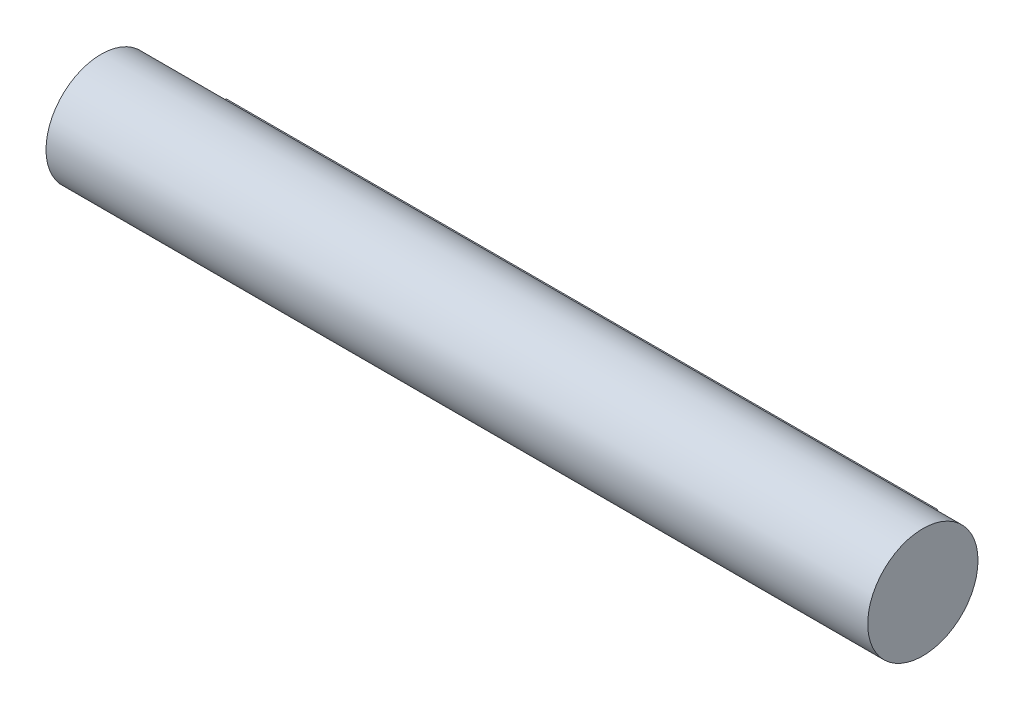
from build123d import *

# Parameters (mm, degrees)
BOSS_EXTRUDE1_DEPTH = 491.49
SKETCH2_R           = 38.1
BOSS_EXTRUDE2_DEPTH = 38.1
SKETCH3_R           = 38.1
BOSS_EXTRUDE3_DEPTH = 38.1


with BuildPart() as part:
    # Sketch1 → Boss-Extrude1 (new body)
    with BuildSketch(Plane(origin=(0, 0, 0), x_dir=(0, 0, -1), z_dir=(1, 0, 0))):
        with BuildLine():
            Line((27.94, 6.35), (27.94, -6.35))
            Line((27.94, -6.35), (37.567106623, -6.35))
            ThreePointArc((37.567106623, -6.35), (37.966542918, -3.186160517), (38.1, 0))
            ThreePointArc((38.1, 0), (37.966542918, 3.186160517), (37.567106623, 6.35))
            Line((37.567106623, 6.35), (27.94, 6.35))
        make_face()
        with BuildLine():
            Line((37.567106623, -6.35), (27.94, -6.35))
            Line((27.94, -6.35), (27.94, 6.35))
            Line((27.94, 6.35), (37.567106623, 6.35))
            ThreePointArc((37.567106623, 6.35), (-38.1, 0), (37.567106623, -6.35))
        make_face()
        with BuildLine():
            ThreePointArc((38.1, 0), (37.966542918, -3.186160517), (37.567106623, -6.35))
            Line((37.567106623, -6.35), (48.26, -6.35))
            Line((48.26, -6.35), (48.26, 6.35))
            Line((48.26, 6.35), (37.567106623, 6.35))
            ThreePointArc((37.567106623, 6.35), (37.966542918, 3.186160517), (38.1, 0))
        make_face()
    extrude(amount=-BOSS_EXTRUDE1_DEPTH)

    # Sketch2 → Boss-Extrude2 (add)
    with BuildSketch(Plane(origin=(0, 0, 0), x_dir=(0, 0, -1), z_dir=(1, 0, 0))):
        Circle(SKETCH2_R)
    extrude(amount=BOSS_EXTRUDE2_DEPTH)

    # Sketch3 → Boss-Extrude3 (add)
    with BuildSketch(Plane.ZY.offset(491.49)):
        Circle(SKETCH3_R)
    extrude(amount=BOSS_EXTRUDE3_DEPTH)


solid = part.part
